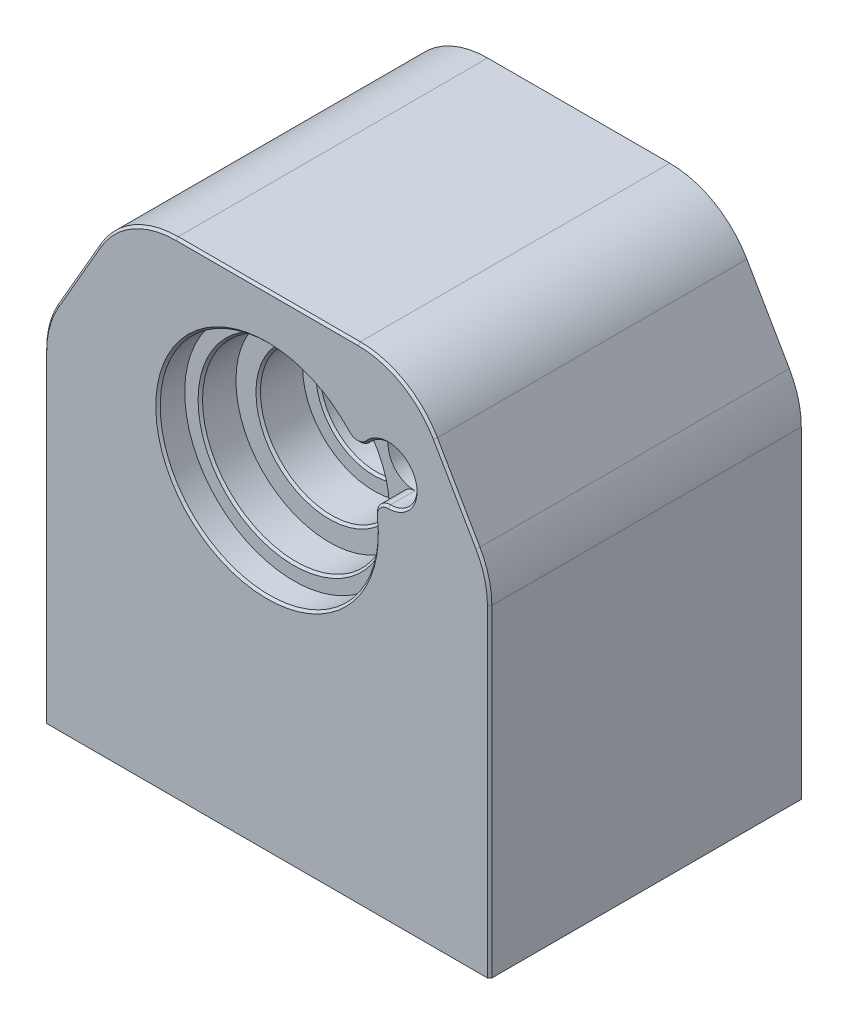
from build123d import *

# Parameters (mm, degrees)
BOSS_EXTRU_1_DEPTH                            = 70
TROU_POUR_TARAUDAGE_POUR_TROU_TARAUD_M1_D     = 10.2
D_GAGEMENT_M121_D                             = 13.5
D_GAGEMENT_M121_DEPTH                         = 40
D_GAGEMENT_M121_TIP                           = 4.055809178
CONG_2_R                                      = 20
ESQUISSE8_R                                   = 10
ENL_V_MAT_EXTRU_2_DEPTH                       = 89
ENL_V_MAT_EXTRU_3_DEPTH                       = 49
CONG_3_R                                      = 4
ESQUISSE10_R                                  = 20
ENL_V_MAT_EXTRU_4_DEPTH                       = 2
TROU_POUR_TARAUDAGE_POUR_TROU_TARAUD_M5_D     = 4.2
TROU_POUR_TARAUDAGE_POUR_TROU_TARAUD_M5_DEPTH = 8
TROU_POUR_TARAUDAGE_POUR_TROU_TARAUD_M5_TIP   = 1.2618073
ESQUISSE15_R                                  = 6
ENL_V_MAT_EXTRU_5_DEPTH                       = 15
CONG_4_R                                      = 3
ENL_V_MAT_EXTRU_6_DEPTH                       = 45
CONG_5_R                                      = 20
CONG_6_R                                      = 6
TROU_POUR_TARAUDAGE_POUR_TROU_TARAUD_2_D      = 4.2
TROU_POUR_TARAUDAGE_POUR_TROU_TARAUD_2_DEPTH  = 30
TROU_POUR_TARAUDAGE_POUR_TROU_TARAUD_2_TIP    = 1.2618073
TROU_POUR_TARAUDAGE_POUR_TROU_TARAUD_M4_D     = 3.3
TROU_POUR_TARAUDAGE_POUR_TROU_TARAUD_M4_DEPTH = 8
TROU_POUR_TARAUDAGE_POUR_TROU_TARAUD_M4_TIP   = 0.991420021
CHANFREIN2_SIZE                               = 0.5
CONG_7_R                                      = 6


with BuildPart() as part:
    # Esquisse1 → Boss.-Extru.1 (new body)
    with BuildSketch(Plane.XY):
        Polygon((32, 35), (-32, 35), (-50, 3.823085464), (-50, -74), (50, -74), (50, 3.823085464), align=None)
    extrude(amount=BOSS_EXTRU_1_DEPTH)

    # Trou pour taraudage pour trou taraudé M121 (through all)
    with Locations(Plane(origin=(0, -30, 0), x_dir=(-1, 0, 0), z_dir=(0, 0, -1))):
        with Locations((-27.189233611, 42.678547852), (0, 30)):
            Hole(TROU_POUR_TARAUDAGE_POUR_TROU_TARAUD_M1_D / 2)

    # Dégagement M121
    with Locations(Plane(origin=(0, 30, 0), x_dir=(1, 0, 0), z_dir=(0, 0, -1))):
        with Locations((27.189233611, 17.321452148)):
            Hole(D_GAGEMENT_M121_D / 2, depth=D_GAGEMENT_M121_DEPTH)
            with Locations((0, 0, -(D_GAGEMENT_M121_DEPTH + D_GAGEMENT_M121_TIP / 2))):  # 118° drill point
                Cone(0, D_GAGEMENT_M121_D / 2, D_GAGEMENT_M121_TIP, mode=Mode.SUBTRACT)

    # Congé2
    cong_2_edges = [part.edges().sort_by_distance(p)[0] for p in [
        (-50, 3.823085464, 35),
        (-32, 35, 35),
        (32, 35, 35),
        (50, 3.823085464, 35),
    ]]
    fillet(cong_2_edges, radius=CONG_2_R)

    # Esquisse8 → Enlèv. mat.-Extru.2 (cut)
    with BuildSketch(Plane.XZ.offset(74)):
        with Locations((-18, 29)):
            Circle(ESQUISSE8_R)
    extrude(amount=-ENL_V_MAT_EXTRU_2_DEPTH, mode=Mode.SUBTRACT)

    # Esquisse9 → Enlèv. mat.-Extru.3 (cut)
    with BuildSketch(Plane.XZ.offset(74)):
        Polygon((-46.500001617, 0.499996766), (-46.500001617, 57.5), (10.499998383, 57.5), (10.499998383, 0.500003234), (10.499998383, 0), (-46.500001617, 0), align=None)
        with BuildLine():
            Line((38, 56.7), (38, 45))
            Line((38, 45), (10, 45))
            Line((10, 45), (10, 56.7))
            ThreePointArc((10, 56.7), (12.928932188, 63.771067812), (20, 66.7))
            Line((20, 66.7), (28, 66.7))
            ThreePointArc((28, 66.7), (35.071067812, 63.771067812), (38, 56.7))
        make_face()
    extrude(amount=-ENL_V_MAT_EXTRU_3_DEPTH, mode=Mode.SUBTRACT)

    # Congé3
    cong_3_edges = [part.edges().sort_by_distance(p)[0] for p in [
        (-46.500001617, -49.5, 57.5),
    ]]
    fillet(cong_3_edges, radius=CONG_3_R)

    # Esquisse10 → Enlèv. mat.-Extru.4 (cut)
    with BuildSketch(Plane.XZ.offset(25)):
        with Locations((-18, 29)):
            Circle(ESQUISSE10_R)
    extrude(amount=-ENL_V_MAT_EXTRU_4_DEPTH, mode=Mode.SUBTRACT)

    # Trou pour taraudage pour trou taraud_ M5
    with Locations(Plane(origin=(0, -25, 0), x_dir=(-1, 0, 0), z_dir=(0, -1, 0))):
        with Locations((-5.57, -52.57), (41.57, -5.43), (41.57, -52.57), (-5.57, -5.43), (18, -29)):
            Hole(TROU_POUR_TARAUDAGE_POUR_TROU_TARAUD_M5_D / 2, depth=TROU_POUR_TARAUDAGE_POUR_TROU_TARAUD_M5_DEPTH)
            with Locations((0, 0, -(TROU_POUR_TARAUDAGE_POUR_TROU_TARAUD_M5_DEPTH + TROU_POUR_TARAUDAGE_POUR_TROU_TARAUD_M5_TIP / 2))):  # 118° drill point
                Cone(0, TROU_POUR_TARAUDAGE_POUR_TROU_TARAUD_M5_D / 2, TROU_POUR_TARAUDAGE_POUR_TROU_TARAUD_M5_TIP, mode=Mode.SUBTRACT)

    # Esquisse14 → Enlèvement de matière-Révolution2 (revolve, cut)
    with BuildSketch(Plane(origin=(0, 0, 0), x_dir=(0, 0, -1), z_dir=(1, 0, 0))):
        Polygon((0, 0), (-70, 0), (-70, 24.5), (-64, 24.5), (-64, 21), (-56, 21), (-56, 16), (-46, 16), (-46, 12.5), (-14.998685055, 12.5), (-14.998685055, 14), (0.001314945, 14), align=None)
    revolve(axis=Axis((0, 0, 0), (0, 0, 1)), mode=Mode.SUBTRACT)

    # Esquisse15 → Enlèv. mat.-Extru.5 (cut)
    with BuildSketch(Plane.XY.offset(70)):
        with Locations((27.189233611, 12.678547852)):
            Circle(ESQUISSE15_R)
    extrude(amount=-ENL_V_MAT_EXTRU_5_DEPTH, mode=Mode.SUBTRACT)

    # Congé4
    cong_4_edges = [part.edges().sort_by_distance(p)[0] for p in [
        (23.032598632, 8.351610639, 67),
        (21.20277394, 12.275682353, 67),
    ]]
    fillet(cong_4_edges, radius=CONG_4_R)

    # Esquisse16 → Enlèv. mat.-Extru.6 (cut)
    with BuildSketch(Plane(origin=(0, 0, 0), x_dir=(-1, 0, 0), z_dir=(0, 0, -1))):
        with BuildLine():
            Line((-38, -74), (-20.439233611, -74))
            Line((-20.439233611, -74), (-10.499998383, -74))
            Line((-10.499998383, -74), (-10.499998383, -25))
            Line((-10.499998383, -25), (-19.189233611, -25))
            Line((-19.189233611, -25), (-19.189233611, 12.678547852))
            ThreePointArc((-19.189233611, 12.678547852), (-25.11868125, 20.405954463), (-34.117436841, 16.678547852))
            Line((-34.117436841, 16.678547852), (-38, 9.953751198))
            Line((-38, 9.953751198), (-38, -74))
        make_face()
    extrude(amount=-ENL_V_MAT_EXTRU_6_DEPTH, mode=Mode.SUBTRACT)

    # Congé5
    cong_5_edges = [part.edges().sort_by_distance(p)[0] for p in [
        (38, 9.953751198, 22.5),
    ]]
    fillet(cong_5_edges, radius=CONG_5_R)

    # Congé6
    cong_6_edges = [part.edges().sort_by_distance(p)[0] for p in [
        (19.189233611, -25, 22.5),
    ]]
    fillet(cong_6_edges, radius=CONG_6_R)

    # Trou pour taraudage pour trou taraud 2
    with Locations(Plane(origin=(0, -74, 0), x_dir=(-1, 0, 0), z_dir=(0, -1, 0))):
        with Locations((44, -64), (-44, -64), (-44, -15)):
            Hole(TROU_POUR_TARAUDAGE_POUR_TROU_TARAUD_2_D / 2, depth=TROU_POUR_TARAUDAGE_POUR_TROU_TARAUD_2_DEPTH)
            with Locations((0, 0, -(TROU_POUR_TARAUDAGE_POUR_TROU_TARAUD_2_DEPTH + TROU_POUR_TARAUDAGE_POUR_TROU_TARAUD_2_TIP / 2))):  # 118° drill point
                Cone(0, TROU_POUR_TARAUDAGE_POUR_TROU_TARAUD_2_D / 2, TROU_POUR_TARAUDAGE_POUR_TROU_TARAUD_2_TIP, mode=Mode.SUBTRACT)

    # Trou pour taraudage pour trou taraudé M41
    with Locations(Plane(origin=(0, 0, 0), x_dir=(-1, 0, 0), z_dir=(0, 0, -1))):
        with Locations((44, -14), (30.845299462, 25), (-30.845299462, 25), (-44, -68)):
            Hole(TROU_POUR_TARAUDAGE_POUR_TROU_TARAUD_M4_D / 2, depth=TROU_POUR_TARAUDAGE_POUR_TROU_TARAUD_M4_DEPTH)
            with Locations((0, 0, -(TROU_POUR_TARAUDAGE_POUR_TROU_TARAUD_M4_DEPTH + TROU_POUR_TARAUDAGE_POUR_TROU_TARAUD_M4_TIP / 2))):  # 118° drill point
                Cone(0, TROU_POUR_TARAUDAGE_POUR_TROU_TARAUD_M4_D / 2, TROU_POUR_TARAUDAGE_POUR_TROU_TARAUD_M4_TIP, mode=Mode.SUBTRACT)

    # Chanfrein2
    chanfrein2_edges = [part.edges().sort_by_distance(p)[0] for p in [
        (50, -37.767949192, 70),
        (0, -14, 0),
        (0, -12.5, 46),
        (0, -21, 64),
        (0, -16, 56),
        (0, -12.5, 14.998685055),
        (-22.204540782, -10.354147413, 70),
        (29.261261506, 18.309418158, 70),
        (20.385817669, 15.512623626, 70),
        (24.987110138, 5.645120084, 70),
        (-50, -37.767949192, 70),
        (-42.547005384, 16.732050808, 70),
        (42.547005384, 16.732050808, 70),
        (0, 35, 70),
        (30.452994616, 32.320508076, 70),
        (-30.452994616, 32.320508076, 70),
        (49.318516526, 3.640482517, 70),
        (-49.318516526, 3.640482517, 70),
    ]]
    chamfer(chanfrein2_edges, length=CHANFREIN2_SIZE)

    # Congé7
    cong_7_edges = [part.edges().sort_by_distance(p)[0] for p in [
        (10.032051364, -49.5, 57.5),
    ]]
    fillet(cong_7_edges, radius=CONG_7_R)


solid = part.part
